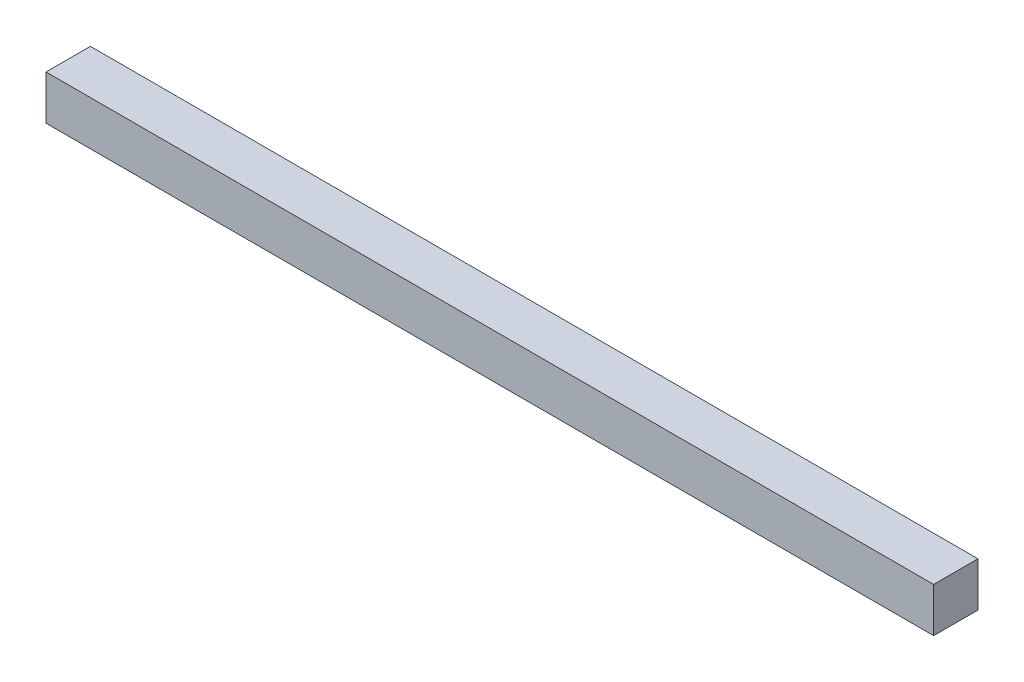
from build123d import *

# Parameters (mm, degrees)
ESQUISSE1_W        = 10000
ESQUISSE1_H        = 500
BOSS_EXTRU_1_DEPTH = 500


with BuildPart() as part:
    # Esquisse1 → Boss.-Extru.1 (new body)
    with BuildSketch(Plane.XY):
        Rectangle(ESQUISSE1_W, ESQUISSE1_H)
    extrude(amount=BOSS_EXTRU_1_DEPTH)


solid = part.part
